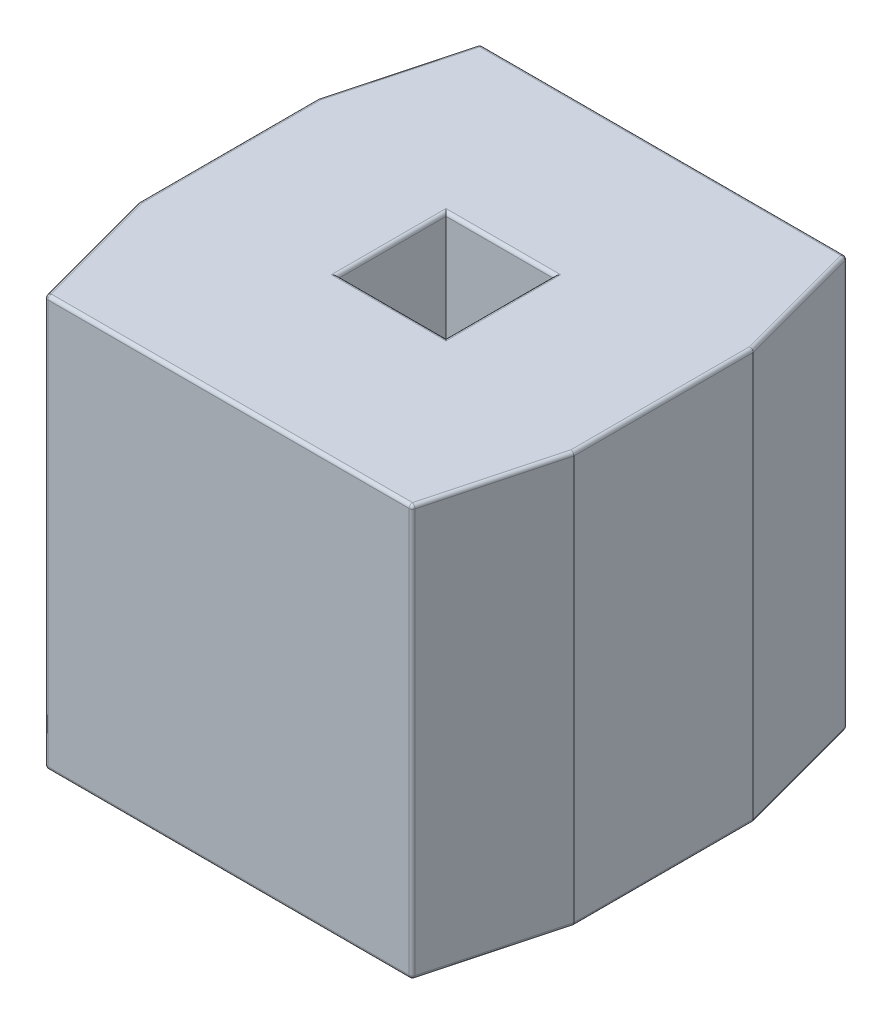
from build123d import *

# Parameters (mm, degrees)
SKETCH1_W             = 2.54
SKETCH1_H             = 2.54
SKETCH1_W_2           = 0.63
SKETCH1_H_2           = 0.63
BOSS_EXTRUDE1_DEPTH   = 2.4
CHAMFER1_SIZE         = 0.2
CHAMFER1_SIZE2        = 0.746410162
CHAMFER1_PART_2_SIZE  = 0.2
CHAMFER1_PART_2_SIZE2 = 0.746410162
FILLET1_R             = 0.02


with BuildPart() as part:
    # Sketch1 → Boss-Extrude1 (new body)
    with BuildSketch(Plane(origin=(0, 0, 0), x_dir=(1, 0, 0), z_dir=(0, 1, 0))):
        Rectangle(SKETCH1_W, SKETCH1_H)
        Rectangle(SKETCH1_W_2, SKETCH1_H_2, mode=Mode.SUBTRACT)
    extrude(amount=BOSS_EXTRUDE1_DEPTH)

    # Chamfer1
    chamfer1_edges = [part.edges().sort_by_distance(p)[0] for p in [
        (1.27, 1.2, 1.27),
        (-1.27, 1.2, 1.27),
    ]]
    chamfer1_side = [part.faces().sort_by_distance(p)[0] for p in [
        (0, 1.2, 1.27),
    ]]
    chamfer(chamfer1_edges, length=CHAMFER1_SIZE, length2=CHAMFER1_SIZE2, reference=chamfer1_side[0])

    # Chamfer1 part 2
    chamfer1_part_2_edges = [part.edges().sort_by_distance(p)[0] for p in [
        (-1.27, 1.2, -1.27),
        (1.27, 1.2, -1.27),
    ]]
    chamfer1_part_2_side = [part.faces().sort_by_distance(p)[0] for p in [
        (0, 1.2, -1.27),
    ]]
    chamfer(chamfer1_part_2_edges, length=CHAMFER1_PART_2_SIZE, length2=CHAMFER1_PART_2_SIZE2, reference=chamfer1_part_2_side[0])

    # Fillet1
    fillet1_edges = [part.edges().sort_by_distance(p)[0] for p in [
        (0.315, 0, 0),
        (0, 0, -0.315),
        (-0.315, 0, 0),
        (0, 0, 0.315),
        (0.315, 2.4, 0),
        (0, 2.4, -0.315),
        (-0.315, 2.4, 0),
        (0, 2.4, 0.315),
        (-1.27, 0, 0),
        (-1.27, 2.4, 0),
        (1.27, 0, 0),
        (0, 0, 1.27),
        (0, 0, -1.27),
        (1.17, 0, 0.896794919),
        (-1.17, 0, 0.896794919),
        (1.17, 0, -0.896794919),
        (-1.17, 0, -0.896794919),
        (0, 2.4, -1.27),
        (1.07, 1.2, -1.27),
        (-1.07, 1.2, -1.27),
        (1.27, 2.4, 0),
        (0, 2.4, 1.27),
        (1.17, 2.4, 0.896794919),
        (-1.17, 2.4, 0.896794919),
        (1.17, 2.4, -0.896794919),
        (-1.17, 2.4, -0.896794919),
        (1.07, 1.2, 1.27),
        (-1.07, 1.2, 1.27),
    ]]
    fillet(fillet1_edges, radius=FILLET1_R)


solid = part.part
